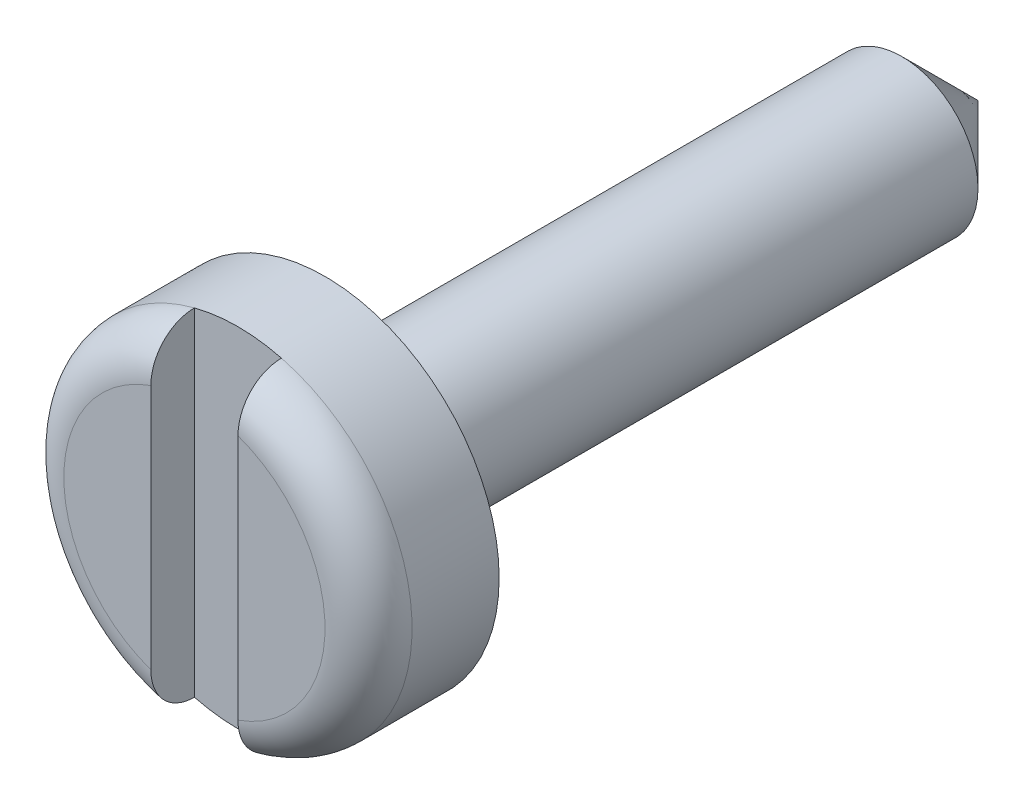
from build123d import *

# Parameters (mm, degrees)
SKICA1_R                 = 1.75
VYSUNOUT1_DEPTH          = 15
SKICA3_R                 = 4
VYSUNOUT2_DEPTH          = 3
ZAOBLIT1_R               = 1
ZKOSIT1_SIZE             = 1.75
SKICA8_W                 = 2
SKICA8_H                 = 8
ODEBRAT_VYSUNUT_M2_DEPTH = 1


with BuildPart() as part:
    # Skica1 → Vysunout1 (new body)
    with BuildSketch(Plane.XY):
        Circle(SKICA1_R)
    extrude(amount=VYSUNOUT1_DEPTH)

    # Skica3 → Vysunout2 (add)
    with BuildSketch(Plane.XY.offset(15)):
        Circle(SKICA3_R)
    extrude(amount=VYSUNOUT2_DEPTH)

    # Zaoblit1
    zaoblit1_edges = [part.edges().sort_by_distance(p)[0] for p in [
        (-4, 0, 18),
    ]]
    fillet(zaoblit1_edges, radius=ZAOBLIT1_R)

    # Zkosit1
    zkosit1_edges = [part.edges().sort_by_distance(p)[0] for p in [
        (-1.75, 0, 0),
    ]]
    chamfer(zkosit1_edges, length=ZKOSIT1_SIZE)

    # Skica8 → Odebrat vysunutím2 (cut)
    with BuildSketch(Plane.XY.offset(18)):
        Rectangle(SKICA8_W, SKICA8_H)
    extrude(amount=-ODEBRAT_VYSUNUT_M2_DEPTH, mode=Mode.SUBTRACT)


solid = part.part
